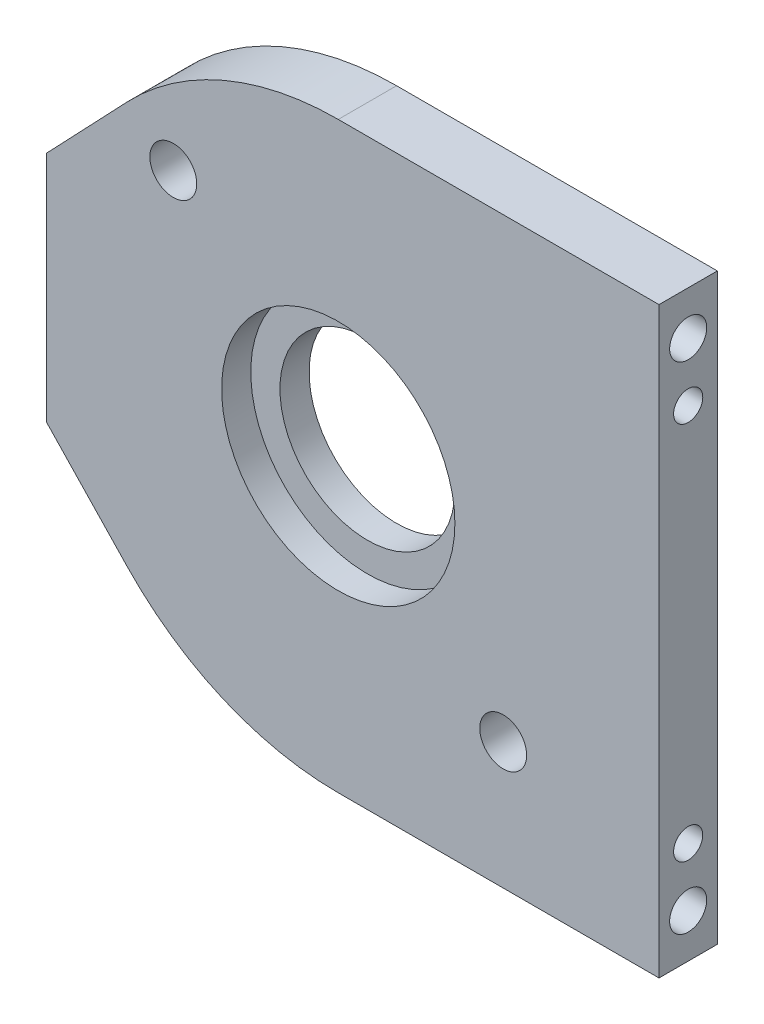
from build123d import *

# Parameters (mm, degrees)
SKETCH1_R                                  = 9.525
BOSS_EXTRUDE1_DEPTH                        = 6.35
F_10_CLEARANCE_HOLE1_D                     = 5.1054
F_1_8_0_125_TRANSITIONAL_DOWEL_HOLE1_D     = 3.175
F_1_8_0_125_TRANSITIONAL_DOWEL_HOLE1_DEPTH = 10.16
F_1_8_0_125_TRANSITIONAL_DOWEL_HOLE1_TIP   = 0.953866233
SKETCH6_R                                  = 12.7
CUT_EXTRUDE1_DEPTH                         = 3.175
F_10_32_TAPPED_HOLE1_D                     = 4.0386
F_10_32_TAPPED_HOLE1_DEPTH                 = 15.748
F_10_32_TAPPED_HOLE1_TIP                   = 1.213317848
F_1_8_0_125_PRESS_DOWEL_HOLE1_D            = 3.175
F_1_8_0_125_PRESS_DOWEL_HOLE1_DEPTH        = 6.35
F_1_8_0_125_PRESS_DOWEL_HOLE1_TIP          = 0.953866233
F_10_32_TAPPED_HOLE2_D                     = 4.0386
F_10_32_TAPPED_HOLE2_DEPTH                 = 15.748
F_10_32_TAPPED_HOLE2_TIP                   = 1.213317848


with BuildPart() as part:
    # Sketch1 → Boss-Extrude1 (new body)
    with BuildSketch(Plane.XY):
        with BuildLine():
            Line((34.925, 31.75), (34.925, -31.75))
            Line((34.925, -31.75), (0, -31.75))
            ThreePointArc((0, -31.75), (-12.50693773, -29.182854703), (-22.99137931, -21.896551724))
            Line((-22.99137931, -21.896551724), (-31.75, -12.7))
            Line((-31.75, -12.7), (-31.75, 12.7))
            Line((-31.75, 12.7), (-22.99137931, 21.896551724))
            ThreePointArc((-22.99137931, 21.896551724), (-12.50693773, 29.182854703), (0, 31.75))
            Line((0, 31.75), (34.925, 31.75))
        make_face()
        Circle(SKETCH1_R, mode=Mode.SUBTRACT)
    extrude(amount=BOSS_EXTRUDE1_DEPTH)

    # #10 Clearance Hole1 (through all)
    with Locations(Plane.XY.offset(6.35)):
        with Locations((17.960512242, -17.960512242), (-17.960512242, 17.960512242)):
            Hole(F_10_CLEARANCE_HOLE1_D / 2)

    # 1/8 (0.125) Transitional Dowel Hole1
    with Locations(Plane(origin=(34.925, 0, 0), x_dir=(0, 0, -1), z_dir=(1, 0, 0))):
        with Locations((-3.175, 20.6375), (-3.175, -20.6375)):
            Hole(F_1_8_0_125_TRANSITIONAL_DOWEL_HOLE1_D / 2, depth=F_1_8_0_125_TRANSITIONAL_DOWEL_HOLE1_DEPTH)
            with Locations((0, 0, -(F_1_8_0_125_TRANSITIONAL_DOWEL_HOLE1_DEPTH + F_1_8_0_125_TRANSITIONAL_DOWEL_HOLE1_TIP / 2))):  # 118° drill point
                Cone(0, F_1_8_0_125_TRANSITIONAL_DOWEL_HOLE1_D / 2, F_1_8_0_125_TRANSITIONAL_DOWEL_HOLE1_TIP, mode=Mode.SUBTRACT)

    # Sketch6 → Cut-Extrude1 (cut)
    with BuildSketch(Plane.XY.offset(6.35)):
        Circle(SKETCH6_R)
    extrude(amount=-CUT_EXTRUDE1_DEPTH, mode=Mode.SUBTRACT)

    # #10-32 Tapped Hole1
    with Locations(Plane(origin=(34.925, 0, 0), x_dir=(0, 0, -1), z_dir=(1, 0, 0))):
        with Locations((-3.175, 26.9875), (-3.175, -26.9875)):
            Hole(F_10_32_TAPPED_HOLE1_D / 2, depth=F_10_32_TAPPED_HOLE1_DEPTH)
            with Locations((0, 0, -(F_10_32_TAPPED_HOLE1_DEPTH + F_10_32_TAPPED_HOLE1_TIP / 2))):  # 118° drill point
                Cone(0, F_10_32_TAPPED_HOLE1_D / 2, F_10_32_TAPPED_HOLE1_TIP, mode=Mode.SUBTRACT)

    # 1/8 (0.125) Press Dowel Hole1
    with Locations(Plane.ZY.offset(31.75)):
        with Locations((3.175, 7.9375), (3.175, -7.9375)):
            Hole(F_1_8_0_125_PRESS_DOWEL_HOLE1_D / 2, depth=F_1_8_0_125_PRESS_DOWEL_HOLE1_DEPTH)
            with Locations((0, 0, -(F_1_8_0_125_PRESS_DOWEL_HOLE1_DEPTH + F_1_8_0_125_PRESS_DOWEL_HOLE1_TIP / 2))):  # 118° drill point
                Cone(0, F_1_8_0_125_PRESS_DOWEL_HOLE1_D / 2, F_1_8_0_125_PRESS_DOWEL_HOLE1_TIP, mode=Mode.SUBTRACT)

    # #10-32 Tapped Hole2
    with Locations(Plane.ZY.offset(31.75)):
        with Locations((3.175, 0)):
            Hole(F_10_32_TAPPED_HOLE2_D / 2, depth=F_10_32_TAPPED_HOLE2_DEPTH)
            with Locations((0, 0, -(F_10_32_TAPPED_HOLE2_DEPTH + F_10_32_TAPPED_HOLE2_TIP / 2))):  # 118° drill point
                Cone(0, F_10_32_TAPPED_HOLE2_D / 2, F_10_32_TAPPED_HOLE2_TIP, mode=Mode.SUBTRACT)


solid = part.part
